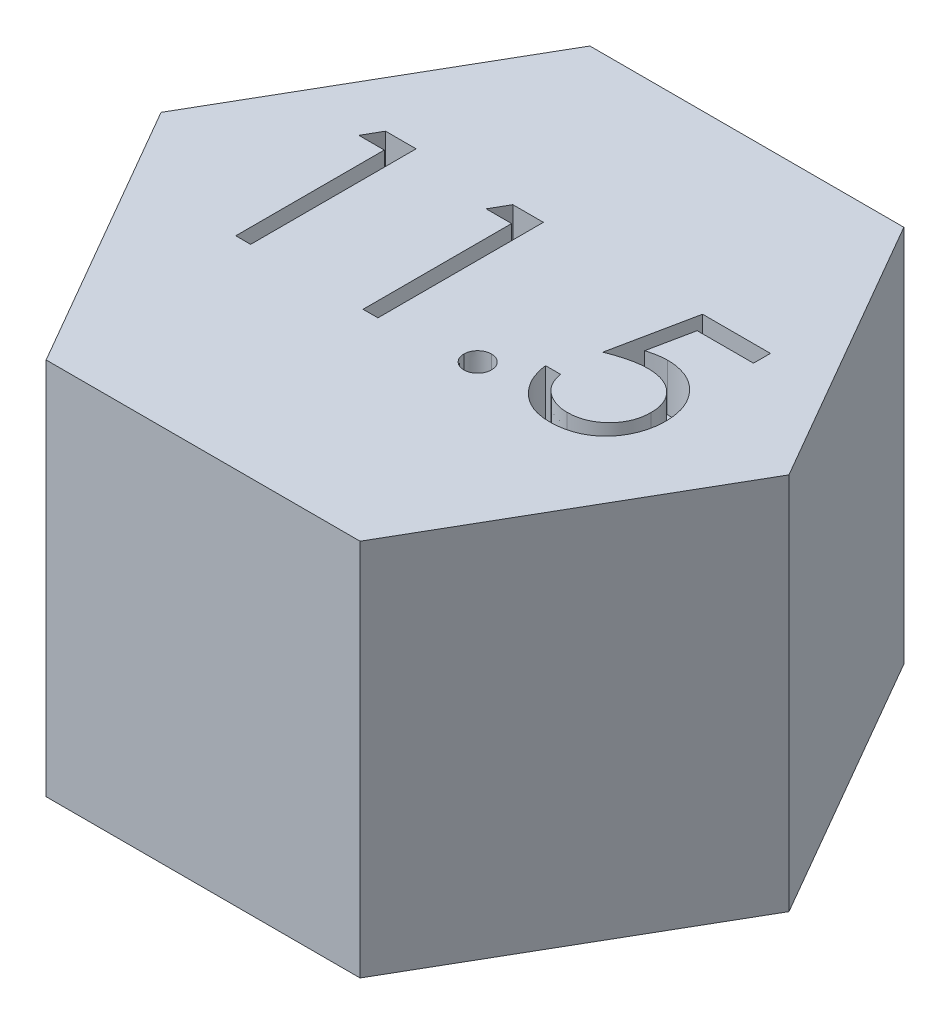
from build123d import *

# Parameters (mm, degrees)
BOSS_EXTRUDE1_DEPTH = 8
CUT_EXTRUDE1_DEPTH  = 1


with BuildPart() as part:
    # Sketch2 → Boss-Extrude1 (new body)
    with BuildSketch(Plane(origin=(0, 0, 0), x_dir=(1, 0, 0), z_dir=(0, 1, 0))):
        Polygon((3.319764048, 5.75), (-3.319764048, 5.75), (-6.639528096, 0), (-3.319764048, -5.75), (3.319764048, -5.75), (6.639528096, 0), align=None)
    extrude(amount=BOSS_EXTRUDE1_DEPTH)

    # Sketch7 → Cut-Extrude1 (cut)
    with BuildSketch(Plane(origin=(0, 8, 0), x_dir=(1, 0, 0), z_dir=(0, 1, 0))):
        Polygon((-3.921529, 2.029099912), (-3.274393584, 2.029099912), (-3.274393584, -1.470900088), (-3.588496148, -1.470900088), (-3.588496148, 1.670125553), (-4.126957686, 1.670125553), align=None)
        Polygon((-1.229221308, 2.029099912), (-0.582085891, 2.029099912), (-0.582085891, -1.470900088), (-0.896188456, -1.470900088), (-0.896188456, 1.670125553), (-1.434649994, 1.670125553), align=None)
        with BuildLine():
            add(Edge.make_bspline(
                [(1.280093596, -0.932438549), (1.299583808, -0.933596716), (1.33779209, -0.935867166), (1.393031219, -0.95144384), (1.443025878, -0.9791025), (1.487558123, -1.015965279), (1.5242646, -1.060660942), (1.552908952, -1.110256851), (1.568349937, -1.165958443), (1.570603849, -1.204388118), (1.571760262, -1.224105216)],
                knots=[0, 0, 0, 0, 5.8463e-05, 0.000114609, 0.000170453, 0.000228714, 0.000286975, 0.000343156, 0.000399303, 0.000458464, 0.000458464, 0.000458464, 0.000458464], degree=3))
            add(Edge.make_bspline(
                [(1.571760262, -1.224105216), (1.570564662, -1.243348546), (1.568206955, -1.281296109), (1.552944346, -1.336577572), (1.524046296, -1.386204476), (1.487811303, -1.431506615), (1.44301487, -1.468447485), (1.392913023, -1.49587083), (1.337921765, -1.51256281), (1.299605442, -1.514689107), (1.280093596, -1.515771883)],
                knots=[0, 0, 0, 0, 5.7765e-05, 0.000113912, 0.000170093, 0.000228896, 0.000287156, 0.000343, 0.000399343, 0.000457806, 0.000457806, 0.000457806, 0.000457806], degree=3))
            add(Edge.make_bspline(
                [(1.280093596, -1.515771883), (1.26056769, -1.514728285), (1.222448007, -1.51269091), (1.167662013, -1.495528104), (1.117255045, -1.468704644), (1.072467333, -1.431437734), (1.035928861, -1.386437591), (1.008303478, -1.336235794), (0.99171333, -1.281454357), (0.989531457, -1.243379714), (0.988426929, -1.224105216)],
                knots=[0, 0, 0, 0, 5.8463e-05, 0.000114135, 0.000170596, 0.000228856, 0.000287659, 0.000343502, 0.000399846, 0.000457611, 0.000457611, 0.000457611, 0.000457611], degree=3))
            add(Edge.make_bspline(
                [(0.988426929, -1.224105216), (0.989489028, -1.204355836), (0.991562647, -1.165797596), (1.008338307, -1.110598489), (1.035714519, -1.060430049), (1.072719914, -1.016033469), (1.11724421, -0.978846167), (1.167540415, -0.951781374), (1.222579955, -0.935740961), (1.260589894, -0.933558445), (1.280093596, -0.932438549)],
                knots=[0, 0, 0, 0, 5.9161e-05, 0.000115504, 0.000171348, 0.000229609, 0.000287869, 0.00034433, 0.000399803, 0.000458266, 0.000458266, 0.000458266, 0.000458266], degree=3))
        make_face()
        with BuildLine():
            Line((4.21919616, 2.029099912), (4.21919616, 1.670125553))
            Line((4.21919616, 1.670125553), (3.028691352, 1.670125553))
            Line((3.028691352, 1.670125553), (2.840089589, 0.749552637))
            add(Edge.make_bspline(
                [(2.840089589, 0.749552637), (2.877145464, 0.759782909), (2.94893536, 0.779602442), (3.054895221, 0.801608213), (3.155487424, 0.814873657), (3.220762794, 0.816684967), (3.252349205, 0.817561451)],
                knots=[0, 0, 0, 0, 0.000115302, 0.000223379, 0.000324431, 0.000419176, 0.000419176, 0.000419176, 0.000419176], degree=3))
            add(Edge.make_bspline(
                [(3.252349205, 0.817561451), (3.291432944, 0.816715515), (3.368281342, 0.815052194), (3.480720289, 0.799080345), (3.588053182, 0.77394043), (3.690055552, 0.738819908), (3.786916103, 0.693910175), (3.877743664, 0.637810235), (3.963901577, 0.572276904), (4.043844171, 0.496931892), (4.116368479, 0.414010275), (4.180134469, 0.324852404), (4.234297059, 0.230324742), (4.277857814, 0.129524133), (4.312642149, 0.02356498), (4.335794143, -0.088667603), (4.351210852, -0.206115723), (4.352933239, -0.286420293), (4.353811544, -0.32737044)],
                knots=[0, 0, 0, 0, 0.00011719, 0.000230425, 0.000339944, 0.000447481, 0.000553499, 0.000659556, 0.000767111, 0.000877722, 0.000988528, 0.001097091, 0.001206056, 0.001314692, 0.001425996, 0.001539995, 0.001658004, 0.001780798, 0.001780798, 0.001780798, 0.001780798], degree=3))
            add(Edge.make_bspline(
                [(4.353811544, -0.32737044), (4.353146469, -0.355892661), (4.351825307, -0.412551648), (4.345106719, -0.496695849), (4.332171003, -0.579058682), (4.314803279, -0.659651074), (4.292260861, -0.738320446), (4.264971807, -0.815291974), (4.231575779, -0.890086581), (4.194944404, -0.963411976), (4.153697926, -1.033610483), (4.107919419, -1.099259469), (4.059553928, -1.161343751), (4.007512542, -1.219197484), (3.951311547, -1.272440502), (3.89163158, -1.321388783), (3.828948861, -1.366870114), (3.762293619, -1.407038309), (3.693151136, -1.444001265), (3.620522919, -1.474324802), (3.546062218, -1.50143533), (3.468697343, -1.523044858), (3.38860353, -1.539977412), (3.305648754, -1.551478013), (3.220268084, -1.55985445), (3.162393072, -1.560378807), (3.1331585, -1.560643677)],
                knots=[0, 0, 0, 0, 8.5583e-05, 0.000170009, 0.000253005, 0.000335518, 0.000417186, 0.000498352, 0.000580291, 0.000662755, 0.000744161, 0.000824288, 0.000902692, 0.000980133, 0.001057498, 0.001134702, 0.00121156, 0.001289599, 0.001368002, 0.001446531, 0.001525481, 0.001605609, 0.001687289, 0.001770875, 0.001856759, 0.001944425, 0.001944425, 0.001944425, 0.001944425], degree=3))
            add(Edge.make_bspline(
                [(3.1331585, -1.560643677), (3.098284319, -1.559952839), (3.029673488, -1.558593697), (2.929152921, -1.544375212), (2.832438315, -1.524011296), (2.740308214, -1.493375026), (2.651936951, -1.454987731), (2.568514233, -1.40647156), (2.487908457, -1.351492456), (2.41339642, -1.286612103), (2.344240307, -1.215696421), (2.282333798, -1.13873878), (2.227200221, -1.057009338), (2.179722474, -0.970111184), (2.139224453, -0.878272653), (2.107409464, -0.781149652), (2.081731109, -0.679249648), (2.070867689, -0.609096137), (2.065350006, -0.57346419)],
                knots=[0, 0, 0, 0, 0.000104552, 0.000205693, 0.000304023, 0.000400691, 0.00049644, 0.000592535, 0.000689779, 0.000788716, 0.000888377, 0.000986596, 0.001084603, 0.001183757, 0.001283279, 0.001385267, 0.001490017, 0.001598135, 0.001598135, 0.001598135, 0.001598135], degree=3))
            Line((2.065350006, -0.57346419), (2.37945257, -0.57346419))
            add(Edge.make_bspline(
                [(2.37945257, -0.57346419), (2.387181128, -0.606840643), (2.402035844, -0.670992038), (2.434641593, -0.761123379), (2.474507468, -0.841442603), (2.521911817, -0.913012186), (2.578461847, -0.975421183), (2.642991276, -1.031038245), (2.715338999, -1.081213374), (2.795732229, -1.123036142), (2.880545308, -1.158704895), (2.969312518, -1.18245659), (3.059616865, -1.199157483), (3.120695235, -1.200829244), (3.151387666, -1.201669318)],
                knots=[0, 0, 0, 0, 0.000102709, 0.000197412, 0.000286774, 0.000371169, 0.000454082, 0.000538572, 0.000626283, 0.000717552, 0.000809994, 0.00090168, 0.00099274, 0.001084718, 0.001084718, 0.001084718, 0.001084718], degree=3))
            add(Edge.make_bspline(
                [(3.151387666, -1.201669318), (3.181346111, -1.20084854), (3.240334533, -1.199232422), (3.32714592, -1.18679341), (3.410958794, -1.167635839), (3.490946151, -1.138965984), (3.56850769, -1.104121265), (3.641681461, -1.059406189), (3.712584338, -1.007946171), (3.779012471, -0.948989541), (3.83985192, -0.884019846), (3.893608042, -0.814542453), (3.938384955, -0.740425606), (3.976119064, -0.662952454), (4.004772363, -0.581273896), (4.025213344, -0.495772721), (4.037216403, -0.406237741), (4.038867583, -0.345168431), (4.03970898, -0.314049126)],
                knots=[0, 0, 0, 0, 8.9842e-05, 0.0001769, 0.000262612, 0.000347317, 0.000431396, 0.000517249, 0.000604055, 0.000693954, 0.000783242, 0.000870748, 0.000956963, 0.001042571, 0.001128832, 0.00121607, 0.001305907, 0.001399251, 0.001399251, 0.001399251, 0.001399251], degree=3))
            add(Edge.make_bspline(
                [(4.03970898, -0.314049126), (4.039050501, -0.285973374), (4.037761621, -0.231019085), (4.027231051, -0.150619879), (4.008914078, -0.074546837), (3.983490198, -0.002432603), (3.951210691, 0.06579084), (3.911764378, 0.1301939), (3.86441098, 0.189927733), (3.810319092, 0.245020287), (3.751061051, 0.295865162), (3.685617308, 0.339209248), (3.615357382, 0.375673166), (3.541127782, 0.407141164), (3.461162883, 0.429741909), (3.377046251, 0.446709795), (3.287869543, 0.456525158), (3.226898855, 0.457887046), (3.195558339, 0.458587092)],
                knots=[0, 0, 0, 0, 8.4208e-05, 0.000164824, 0.000242709, 0.000318547, 0.000393815, 0.000468731, 0.000544614, 0.00062196, 0.000700062, 0.000778428, 0.000856831, 0.000937299, 0.001019835, 0.001105635, 0.00119452, 0.001288536, 0.001288536, 0.001288536, 0.001288536], degree=3))
            add(Edge.make_bspline(
                [(3.195558339, 0.458587092), (3.168429411, 0.458006501), (3.112415055, 0.456807727), (3.026492228, 0.44798123), (2.936200506, 0.433741936), (2.84188601, 0.414155689), (2.743265502, 0.388524612), (2.640547101, 0.357810111), (2.533514835, 0.321088112), (2.46139711, 0.293355899), (2.424324365, 0.279099912)],
                knots=[0, 0, 0, 0, 8.1378e-05, 0.000168026, 0.000258858, 0.000355524, 0.000456875, 0.000564457, 0.000677092, 0.000796243, 0.000796243, 0.000796243, 0.000796243], degree=3))
            Line((2.424324365, 0.279099912), (2.783298724, 2.029099912))
            Line((2.783298724, 2.029099912), (4.21919616, 2.029099912))
        make_face()
    extrude(amount=-CUT_EXTRUDE1_DEPTH, mode=Mode.SUBTRACT)


solid = part.part
